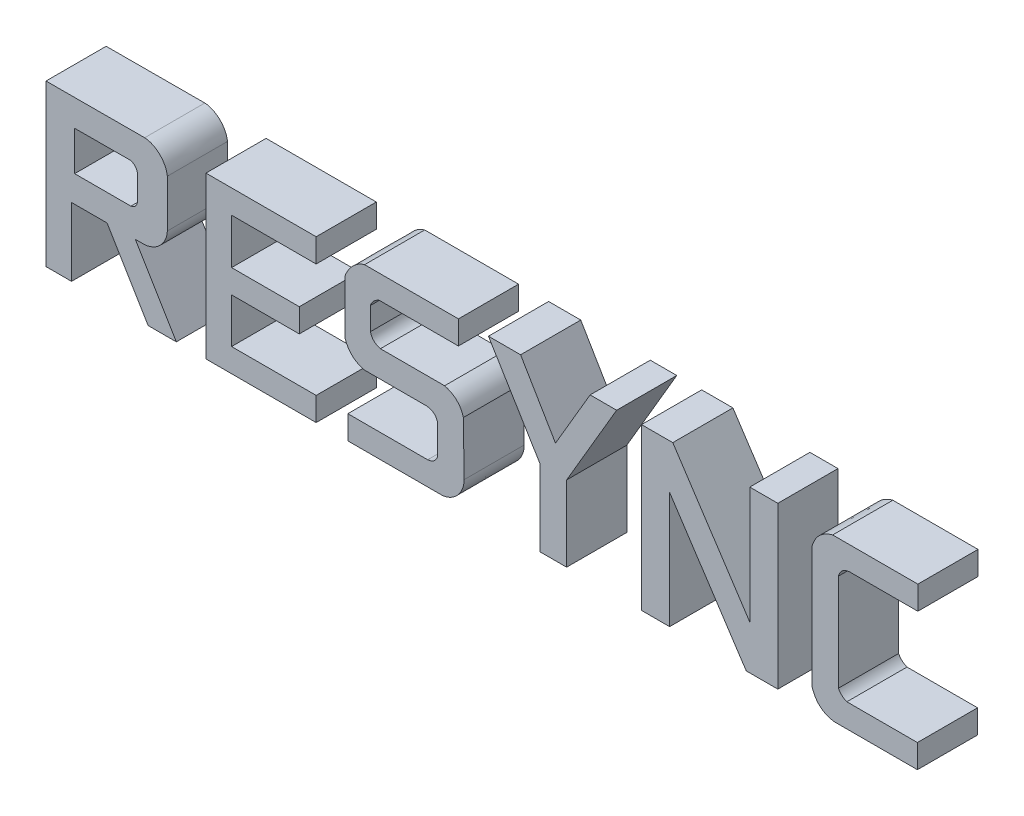
from build123d import *

# Parameters (mm, degrees)
BOSS_EXTRUDE8_DEPTH   = 2
BOSS_EXTRUDE8_2_DEPTH = 2
BOSS_EXTRUDE8_3_DEPTH = 2
BOSS_EXTRUDE8_4_DEPTH = 2
BOSS_EXTRUDE8_5_DEPTH = 2
BOSS_EXTRUDE8_6_DEPTH = 2


with BuildPart() as part:
    # Sketch39 → Boss-Extrude8 (new body)
    with BuildSketch(Plane.XY):
        with BuildLine():
            Line((-10.888283658, 4.549273437), (-10.888283658, 6.126987026))
            add(Edge.make_bspline(
                [(-10.888283658, 6.126987026), (-10.908232756, 6.311540114), (-11.094852516, 6.669600397), (-11.456841906, 6.846838223), (-11.641186102, 6.857619555)],
                knots=[0.004357591, 0.004357591, 0.004357591, 0.004357591, 0.500967638, 0.997577686, 0.997577686, 0.997577686, 0.997577686], degree=3))
            Line((-11.641186102, 6.857619555), (-14.922474371, 6.850388867))
            Line((-14.922474371, 6.850388867), (-14.922474371, 1.505742473))
            Line((-14.922474371, 1.505742473), (-14.072776349, 1.505742473))
            Line((-14.072776349, 1.505742473), (-14.072776349, 3.777872176))
            Line((-14.072776349, 3.777872176), (-12.891259134, 3.777872176))
            Line((-12.891259134, 3.777872176), (-11.52653581, 1.505742473))
            Line((-11.52653581, 1.505742473), (-10.588770825, 1.505742473))
            Line((-10.588770825, 1.505742473), (-11.953494149, 3.777872176))
            Line((-11.953494149, 3.777872176), (-11.642084885, 3.777872176))
            add(Edge.make_bspline(
                [(-11.642084885, 3.777872176), (-11.451993433, 3.792046974), (-11.074843016, 3.966339896), (-10.894872856, 4.35631666), (-10.888283658, 4.549273437)],
                knots=[0.002906528, 0.002906528, 0.002906528, 0.002906528, 0.500827012, 0.998747497, 0.998747497, 0.998747497, 0.998747497], degree=3))
        make_face()
        with BuildLine():
            add(Edge.make_bspline(
                [(-11.884951007, 5.735076037), (-11.928592054, 5.922883289), (-12.120490935, 5.97197097)],
                knots=[0, 0, 0, 1, 1, 1], degree=2))
            Line((-12.120490935, 5.97197097), (-13.972776349, 5.964685241))
            Line((-13.972776349, 5.964685241), (-13.969898423, 4.658681327))
            Line((-13.969898423, 4.658681327), (-12.098915788, 4.658681327))
            add(Edge.make_bspline(
                [(-12.098915788, 4.658681327), (-11.921884887, 4.693884027), (-11.884951007, 4.869171619)],
                knots=[0, 0, 0, 1, 1, 1], degree=2))
            Line((-11.884951007, 4.869171619), (-11.884951007, 5.735076037))
        make_face(mode=Mode.SUBTRACT)
    extrude(amount=BOSS_EXTRUDE8_DEPTH)


with BuildPart() as body_2:
    # Sketch39 → Boss-Extrude8 2 (new body)
    with BuildSketch(Plane.XY):
        Polygon((-8.752624131, 6.07197097), (-5.94007284, 6.07197097), (-5.94007284, 6.857625765), (-9.60478091, 6.857625765), (-9.60478091, 1.505742473), (-5.94007284, 1.505742473), (-5.94007284, 2.289085691), (-8.752624131, 2.289085691), (-8.752624131, 3.777872176), (-6.500945529, 3.777872176), (-6.500945529, 4.562436919), (-8.752624131, 4.562436919), align=None)
    extrude(amount=BOSS_EXTRUDE8_2_DEPTH)


with BuildPart() as body_3:
    # Sketch39 → Boss-Extrude8 3 (new body)
    with BuildSketch(Plane.XY):
        with BuildLine():
            Line((-4.331445745, 3.821709693), (-2.267474021, 3.821709693))
            add(Edge.make_bspline(
                [(-2.267474021, 3.821709693), (-2.18188065, 3.81593612), (-2.001029862, 3.760941511), (-1.918852857, 3.596190197), (-1.897178545, 3.514314513)],
                knots=[-0.007665862, -0.007665862, -0.007665862, -0.007665862, 0.511460783, 1.030587427, 1.030587427, 1.030587427, 1.030587427], degree=3))
            Line((-1.897178545, 3.514314513), (-1.897178545, 2.559561474))
            add(Edge.make_bspline(
                [(-1.897178545, 2.559561474), (-1.920997625, 2.488393268), (-1.997915919, 2.347168794), (-2.155599312, 2.295866478), (-2.231249257, 2.289085691)],
                knots=[-0.045302285, -0.045302285, -0.045302285, -0.045302285, 0.483485723, 1.01227373, 1.01227373, 1.01227373, 1.01227373], degree=3))
            Line((-2.231249257, 2.289085691), (-4.88659772, 2.289085691))
            Line((-4.88659772, 2.289085691), (-4.88659772, 1.505742473))
            Line((-4.88659772, 1.505742473), (-1.747765617, 1.505742473))
            add(Edge.make_bspline(
                [(-1.747765617, 1.505742473), (-1.554039499, 1.522473909), (-1.176105355, 1.730633067), (-1.019975744, 2.125993011), (-1.022239558, 2.319749566)],
                knots=[0.003205409, 0.003205409, 0.003205409, 0.003205409, 0.501602705, 1, 1, 1, 1], degree=3))
            Line((-1.022239558, 2.319749566), (-1.043051423, 4.10100641))
            add(Edge.make_bspline(
                [(-1.043051423, 4.10100641), (-1.065619796, 4.176263738), (-1.129917251, 4.327916486), (-1.262718984, 4.49362296), (-1.434645881, 4.620744007), (-1.591738794, 4.681150616), (-1.669091916, 4.701815782)],
                knots=[0.012743608, 0.012743608, 0.012743608, 0.012743608, 0.256640139, 0.500536671, 0.744433202, 0.988329734, 0.988329734, 0.988329734, 0.988329734], degree=3))
            Line((-1.669091916, 4.701815782), (-3.80345691, 4.701815782))
            add(Edge.make_bspline(
                [(-3.80345691, 4.701815782), (-3.881648249, 4.721973704), (-4.038081478, 4.794101762), (-4.114162603, 4.947083549), (-4.136596871, 5.024268339)],
                knots=[-0.032088246, -0.032088246, -0.032088246, -0.032088246, 0.502199739, 1.036487723, 1.036487723, 1.036487723, 1.036487723], degree=3))
            Line((-4.136596871, 5.024268339), (-4.136596871, 5.779216833))
            add(Edge.make_bspline(
                [(-4.136596871, 5.779216833), (-4.09320159, 5.910957545), (-3.975516536, 6.029193296), (-3.844958381, 6.076026335)],
                knots=[-0.048739002, -0.048739002, -0.048739002, -0.048739002, 1.051963254, 1.051963254, 1.051963254, 1.051963254], degree=3))
            Line((-3.844958381, 6.076026335), (-1.209628903, 6.076026335))
            Line((-1.209628903, 6.076026335), (-1.209628903, 6.857625765))
            Line((-1.209628903, 6.857625765), (-4.33068222, 6.857625765))
            add(Edge.make_bspline(
                [(-4.33068222, 6.857625765), (-4.628207422, 6.779563045), (-4.88190688, 6.495297474), (-4.98278942, 6.204715734)],
                knots=[0.011688933, 0.011688933, 0.011688933, 0.011688933, 0.984045744, 0.984045744, 0.984045744, 0.984045744], degree=3))
            Line((-4.98278942, 6.204715734), (-4.98278942, 4.429589182))
            add(Edge.make_bspline(
                [(-4.98278942, 4.429589182), (-4.957928137, 4.351858109), (-4.888451922, 4.195176517), (-4.749030804, 4.026321893), (-4.57111561, 3.899076851), (-4.410501277, 3.840956124), (-4.331445745, 3.821709693)],
                knots=[0.013618493, 0.013618493, 0.013618493, 0.013618493, 0.257585504, 0.501552515, 0.745519526, 0.989486537, 0.989486537, 0.989486537, 0.989486537], degree=3))
        make_face()
    extrude(amount=BOSS_EXTRUDE8_3_DEPTH)


with BuildPart() as body_4:
    # Sketch39 → Boss-Extrude8 4 (new body)
    with BuildSketch(Plane.XY):
        Polygon((8.476971429, 6.857625765), (8.476971429, 2.97350344), (5.917175659, 6.857625765), (4.878705551, 6.857625765), (4.878705551, 1.505742473), (5.812405759, 1.505742473), (5.812405759, 5.371966432), (8.360405772, 1.505742473), (9.410671637, 1.505742473), (9.410671637, 6.857625765), align=None)
    extrude(amount=BOSS_EXTRUDE8_4_DEPTH)


with BuildPart() as body_5:
    # Sketch39 → Boss-Extrude8 5 (new body)
    with BuildSketch(Plane.XY):
        with BuildLine():
            add(Edge.make_bspline(
                [(11.282902439, 1.505742473), (11.19415179, 1.518984982), (11.011088341, 1.568898827), (10.811389164, 1.698145446), (10.65406452, 1.880985323), (10.574750759, 2.06184818), (10.547050594, 2.150621319)],
                knots=[0.005888611, 0.005888611, 0.005888611, 0.005888611, 0.251501652, 0.497114693, 0.742727735, 0.988340776, 0.988340776, 0.988340776, 0.988340776], degree=3))
            Line((10.547050594, 2.150621319), (10.547050594, 6.190146216))
            add(Edge.make_bspline(
                [(10.547050594, 6.190146216), (10.571669638, 6.27393603), (10.642083437, 6.443109543), (10.787921904, 6.627705307), (10.976703119, 6.768698533), (11.148490286, 6.83502177), (11.233236627, 6.857625765)],
                knots=[0.011813784, 0.011813784, 0.011813784, 0.011813784, 0.25618025, 0.500546716, 0.744913182, 0.989279648, 0.989279648, 0.989279648, 0.989279648], degree=3))
            Line((11.233236627, 6.857625765), (14.065921312, 6.857625765))
            Line((14.065921312, 6.857625765), (14.065921312, 6.076026335))
            Line((14.065921312, 6.076026335), (11.799717704, 6.076026335))
            add(Edge.make_bspline(
                [(11.799717704, 6.076026335), (11.713521041, 6.070666208), (11.531507403, 6.015572919), (11.447768348, 5.849791271), (11.425043158, 5.767354498)],
                knots=[-0.007036339, -0.007036339, -0.007036339, -0.007036339, 0.512122438, 1.031281215, 1.031281215, 1.031281215, 1.031281215], degree=3))
            Line((11.425043158, 5.767354498), (11.425043158, 2.53928051))
            add(Edge.make_bspline(
                [(11.425043158, 2.53928051), (11.481020414, 2.427440582), (11.586582072, 2.330350466), (11.704644941, 2.289085691)],
                knots=[-0.082922559, -0.082922559, -0.082922559, -0.082922559, 1.060320703, 1.060320703, 1.060320703, 1.060320703], degree=3))
            Line((11.704644941, 2.289085691), (14.051295186, 2.289085691))
            Line((14.051295186, 2.289085691), (14.051295186, 1.505742473))
            Line((14.051295186, 1.505742473), (11.282902439, 1.505742473))
        make_face()
    extrude(amount=BOSS_EXTRUDE8_5_DEPTH)


with BuildPart() as body_6:
    # Sketch39 → Boss-Extrude8 6 (new body)
    with BuildSketch(Plane.XY):
        Polygon((2.017682999, 4.891885001), (0.857379848, 6.857625765), (-0.211164194, 6.857625765), (1.498107647, 4.050537974), (1.498107647, 1.505742473), (2.388128238, 1.505742473), (2.388128238, 4.019029191), (4.05062916, 6.857625765), (3.16897229, 6.857625765), align=None)
    extrude(amount=BOSS_EXTRUDE8_6_DEPTH)


solid = Compound([part.part, body_2.part, body_3.part, body_4.part, body_5.part, body_6.part])
